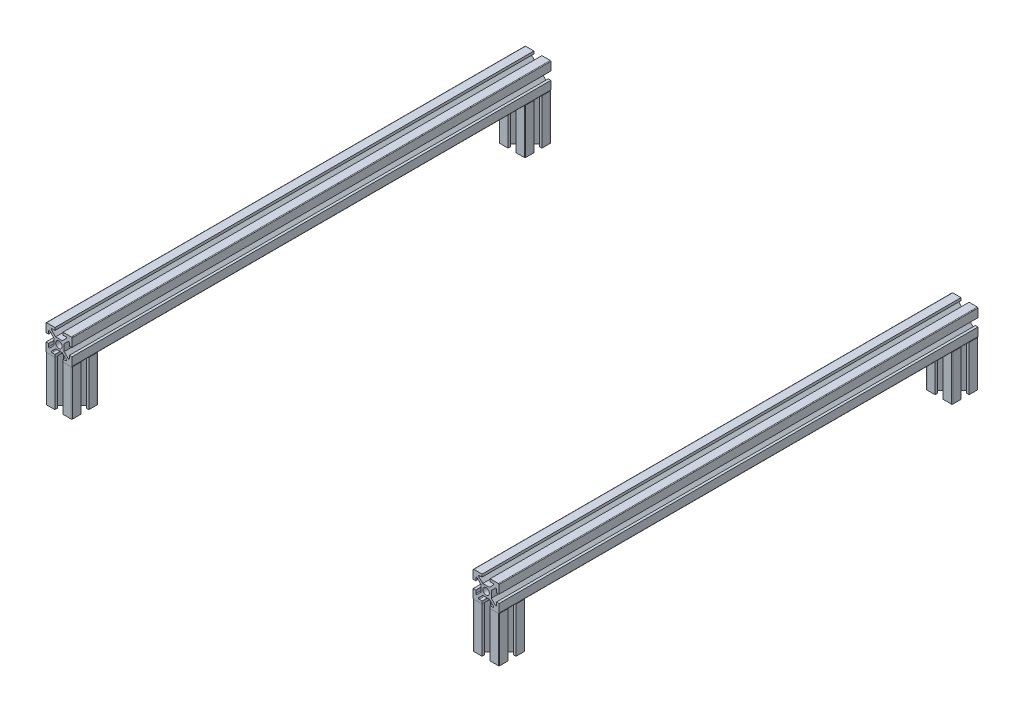
from build123d import *

# Parameters (mm, degrees)
SKETCH1_R                       = 2.5
AL_EXTRUSION_20X20_1_DEPTH      = 360
AL_EXTRUSION_20X20_1_DEPTH_BACK = 10
SKETCH1_ON_SEGMENT_2_R          = 2.5
AL_EXTRUSION_20X20_1_2_DEPTH    = 370
SKETCH1_ON_SEGMENT_3_R          = 2.5
AL_EXTRUSION_20X20_1_3_DEPTH    = 46
SKETCH1_ON_SEGMENT_4_R          = 2.5
AL_EXTRUSION_20X20_1_4_DEPTH    = 46
SKETCH1_ON_SEGMENT_5_R          = 2.5
AL_EXTRUSION_20X20_1_5_DEPTH    = 46
SKETCH1_ON_SEGMENT_6_R          = 2.5
AL_EXTRUSION_20X20_1_6_DEPTH    = 46


with BuildPart() as part:
    # Sketch1 → Al extrusion 20X20(1) (new, two sides)
    with BuildSketch(Plane(origin=(-165, 0, -175), x_dir=(1, 0, 0), z_dir=(0, 0, 1))) as al_extrusion_20x20_1_sk:
        with BuildLine():
            Line((-9.5, 10), (-3.1, 10))
            Line((-3.1, 10), (-3.1, 8))
            Line((-3.1, 8), (-5.378679656, 8))
            ThreePointArc((-5.378679656, 8), (-5.840619423, 7.691341716), (-5.732233047, 7.146446609))
            Line((-5.732233047, 7.146446609), (-2.585786438, 4))
            Line((-2.585786438, 4), (2.585786438, 4))
            Line((2.585786438, 4), (5.732233047, 7.146446609))
            ThreePointArc((5.732233047, 7.146446609), (5.840619423, 7.691341716), (5.378679656, 8))
            Line((5.378679656, 8), (3.1, 8))
            Line((3.1, 8), (3.1, 10))
            Line((3.1, 10), (9.5, 10))
            ThreePointArc((9.5, 10), (9.853553391, 9.853553391), (10, 9.5))
            Line((10, 9.5), (10, 3.1))
            Line((10, 3.1), (8, 3.1))
            Line((8, 3.1), (8, 5.378679656))
            ThreePointArc((8, 5.378679656), (7.691341716, 5.840619423), (7.146446609, 5.732233047))
            Line((7.146446609, 5.732233047), (4, 2.585786438))
            Line((4, 2.585786438), (4, -2.585786438))
            Line((4, -2.585786438), (7.146446609, -5.732233047))
            ThreePointArc((7.146446609, -5.732233047), (7.691341716, -5.840619423), (8, -5.378679656))
            Line((8, -5.378679656), (8, -3.1))
            Line((8, -3.1), (10, -3.1))
            Line((10, -3.1), (10, -9.5))
            ThreePointArc((10, -9.5), (9.853553391, -9.853553391), (9.5, -10))
            Line((9.5, -10), (3.1, -10))
            Line((3.1, -10), (3.1, -8))
            Line((3.1, -8), (5.378679656, -8))
            ThreePointArc((5.378679656, -8), (5.840619423, -7.691341716), (5.732233047, -7.146446609))
            Line((5.732233047, -7.146446609), (2.585786438, -4))
            Line((2.585786438, -4), (-2.585786438, -4))
            Line((-2.585786438, -4), (-5.732233047, -7.146446609))
            ThreePointArc((-5.732233047, -7.146446609), (-5.840619423, -7.691341716), (-5.378679656, -8))
            Line((-5.378679656, -8), (-3.1, -8))
            Line((-3.1, -8), (-3.1, -10))
            Line((-3.1, -10), (-9.5, -10))
            ThreePointArc((-9.5, -10), (-9.853553391, -9.853553391), (-10, -9.5))
            Line((-10, -9.5), (-10, -3.1))
            Line((-10, -3.1), (-8, -3.1))
            Line((-8, -3.1), (-8, -5.378679656))
            ThreePointArc((-8, -5.378679656), (-7.691341716, -5.840619423), (-7.146446609, -5.732233047))
            Line((-7.146446609, -5.732233047), (-4, -2.585786438))
            Line((-4, -2.585786438), (-4, 2.585786438))
            Line((-4, 2.585786438), (-7.146446609, 5.732233047))
            ThreePointArc((-7.146446609, 5.732233047), (-7.691341716, 5.840619423), (-8, 5.378679656))
            Line((-8, 5.378679656), (-8, 3.1))
            Line((-8, 3.1), (-10, 3.1))
            Line((-10, 3.1), (-10, 9.5))
            ThreePointArc((-10, 9.5), (-9.853553391, 9.853553391), (-9.5, 10))
        make_face()
        Circle(SKETCH1_R, mode=Mode.SUBTRACT)
    extrude(amount=AL_EXTRUSION_20X20_1_DEPTH)
    extrude(al_extrusion_20x20_1_sk.sketch, amount=-AL_EXTRUSION_20X20_1_DEPTH_BACK)


with BuildPart() as body_2:
    # Sketch1 on segment 2 (carried to segment 2) → Al extrusion 20X20_1 2 (new body)
    with BuildSketch(Plane(origin=(165, 0, -185), x_dir=(1, 0, 0), z_dir=(0, 0, 1))):
        with BuildLine():
            Line((-9.5, 10), (-3.1, 10))
            Line((-3.1, 10), (-3.1, 8))
            Line((-3.1, 8), (-5.378679656, 8))
            ThreePointArc((-5.378679656, 8), (-5.840619423, 7.691341716), (-5.732233047, 7.146446609))
            Line((-5.732233047, 7.146446609), (-2.585786438, 4))
            Line((-2.585786438, 4), (2.585786438, 4))
            Line((2.585786438, 4), (5.732233047, 7.146446609))
            ThreePointArc((5.732233047, 7.146446609), (5.840619423, 7.691341716), (5.378679656, 8))
            Line((5.378679656, 8), (3.1, 8))
            Line((3.1, 8), (3.1, 10))
            Line((3.1, 10), (9.5, 10))
            ThreePointArc((9.5, 10), (9.853553391, 9.853553391), (10, 9.5))
            Line((10, 9.5), (10, 3.1))
            Line((10, 3.1), (8, 3.1))
            Line((8, 3.1), (8, 5.378679656))
            ThreePointArc((8, 5.378679656), (7.691341716, 5.840619423), (7.146446609, 5.732233047))
            Line((7.146446609, 5.732233047), (4, 2.585786438))
            Line((4, 2.585786438), (4, -2.585786438))
            Line((4, -2.585786438), (7.146446609, -5.732233047))
            ThreePointArc((7.146446609, -5.732233047), (7.691341716, -5.840619423), (8, -5.378679656))
            Line((8, -5.378679656), (8, -3.1))
            Line((8, -3.1), (10, -3.1))
            Line((10, -3.1), (10, -9.5))
            ThreePointArc((10, -9.5), (9.853553391, -9.853553391), (9.5, -10))
            Line((9.5, -10), (3.1, -10))
            Line((3.1, -10), (3.1, -8))
            Line((3.1, -8), (5.378679656, -8))
            ThreePointArc((5.378679656, -8), (5.840619423, -7.691341716), (5.732233047, -7.146446609))
            Line((5.732233047, -7.146446609), (2.585786438, -4))
            Line((2.585786438, -4), (-2.585786438, -4))
            Line((-2.585786438, -4), (-5.732233047, -7.146446609))
            ThreePointArc((-5.732233047, -7.146446609), (-5.840619423, -7.691341716), (-5.378679656, -8))
            Line((-5.378679656, -8), (-3.1, -8))
            Line((-3.1, -8), (-3.1, -10))
            Line((-3.1, -10), (-9.5, -10))
            ThreePointArc((-9.5, -10), (-9.853553391, -9.853553391), (-10, -9.5))
            Line((-10, -9.5), (-10, -3.1))
            Line((-10, -3.1), (-8, -3.1))
            Line((-8, -3.1), (-8, -5.378679656))
            ThreePointArc((-8, -5.378679656), (-7.691341716, -5.840619423), (-7.146446609, -5.732233047))
            Line((-7.146446609, -5.732233047), (-4, -2.585786438))
            Line((-4, -2.585786438), (-4, 2.585786438))
            Line((-4, 2.585786438), (-7.146446609, 5.732233047))
            ThreePointArc((-7.146446609, 5.732233047), (-7.691341716, 5.840619423), (-8, 5.378679656))
            Line((-8, 5.378679656), (-8, 3.1))
            Line((-8, 3.1), (-10, 3.1))
            Line((-10, 3.1), (-10, 9.5))
            ThreePointArc((-10, 9.5), (-9.853553391, 9.853553391), (-9.5, 10))
        make_face()
        Circle(SKETCH1_ON_SEGMENT_2_R, mode=Mode.SUBTRACT)
    extrude(amount=AL_EXTRUSION_20X20_1_2_DEPTH)


with BuildPart() as body_3:
    # Sketch1 on segment 3 (carried to segment 3) → Al extrusion 20X20_1 3 (new body)
    with BuildSketch(Plane(origin=(-165, 1, 175), x_dir=(1, 0, 0), z_dir=(0, -1, 0))):
        with BuildLine():
            Line((-9.5, 10), (-3.1, 10))
            Line((-3.1, 10), (-3.1, 8))
            Line((-3.1, 8), (-5.378679656, 8))
            ThreePointArc((-5.378679656, 8), (-5.840619423, 7.691341716), (-5.732233047, 7.146446609))
            Line((-5.732233047, 7.146446609), (-2.585786438, 4))
            Line((-2.585786438, 4), (2.585786438, 4))
            Line((2.585786438, 4), (5.732233047, 7.146446609))
            ThreePointArc((5.732233047, 7.146446609), (5.840619423, 7.691341716), (5.378679656, 8))
            Line((5.378679656, 8), (3.1, 8))
            Line((3.1, 8), (3.1, 10))
            Line((3.1, 10), (9.5, 10))
            ThreePointArc((9.5, 10), (9.853553391, 9.853553391), (10, 9.5))
            Line((10, 9.5), (10, 3.1))
            Line((10, 3.1), (8, 3.1))
            Line((8, 3.1), (8, 5.378679656))
            ThreePointArc((8, 5.378679656), (7.691341716, 5.840619423), (7.146446609, 5.732233047))
            Line((7.146446609, 5.732233047), (4, 2.585786438))
            Line((4, 2.585786438), (4, -2.585786438))
            Line((4, -2.585786438), (7.146446609, -5.732233047))
            ThreePointArc((7.146446609, -5.732233047), (7.691341716, -5.840619423), (8, -5.378679656))
            Line((8, -5.378679656), (8, -3.1))
            Line((8, -3.1), (10, -3.1))
            Line((10, -3.1), (10, -9.5))
            ThreePointArc((10, -9.5), (9.853553391, -9.853553391), (9.5, -10))
            Line((9.5, -10), (3.1, -10))
            Line((3.1, -10), (3.1, -8))
            Line((3.1, -8), (5.378679656, -8))
            ThreePointArc((5.378679656, -8), (5.840619423, -7.691341716), (5.732233047, -7.146446609))
            Line((5.732233047, -7.146446609), (2.585786438, -4))
            Line((2.585786438, -4), (-2.585786438, -4))
            Line((-2.585786438, -4), (-5.732233047, -7.146446609))
            ThreePointArc((-5.732233047, -7.146446609), (-5.840619423, -7.691341716), (-5.378679656, -8))
            Line((-5.378679656, -8), (-3.1, -8))
            Line((-3.1, -8), (-3.1, -10))
            Line((-3.1, -10), (-9.5, -10))
            ThreePointArc((-9.5, -10), (-9.853553391, -9.853553391), (-10, -9.5))
            Line((-10, -9.5), (-10, -3.1))
            Line((-10, -3.1), (-8, -3.1))
            Line((-8, -3.1), (-8, -5.378679656))
            ThreePointArc((-8, -5.378679656), (-7.691341716, -5.840619423), (-7.146446609, -5.732233047))
            Line((-7.146446609, -5.732233047), (-4, -2.585786438))
            Line((-4, -2.585786438), (-4, 2.585786438))
            Line((-4, 2.585786438), (-7.146446609, 5.732233047))
            ThreePointArc((-7.146446609, 5.732233047), (-7.691341716, 5.840619423), (-8, 5.378679656))
            Line((-8, 5.378679656), (-8, 3.1))
            Line((-8, 3.1), (-10, 3.1))
            Line((-10, 3.1), (-10, 9.5))
            ThreePointArc((-10, 9.5), (-9.853553391, 9.853553391), (-9.5, 10))
        make_face()
        Circle(SKETCH1_ON_SEGMENT_3_R, mode=Mode.SUBTRACT)
    extrude(amount=AL_EXTRUSION_20X20_1_3_DEPTH)

    # Al extrusion 20X20_1 3 end butt 1
    split(bisect_by=Plane(origin=(-165, -10, 175), x_dir=(1, 0, 0), z_dir=(0, -1, 0)), keep=Keep.TOP)


with BuildPart() as body_4:
    # Sketch1 on segment 4 (carried to segment 4) → Al extrusion 20X20_1 4 (new body)
    with BuildSketch(Plane(origin=(-165, 1, -175), x_dir=(1, 0, 0), z_dir=(0, -1, 0))):
        with BuildLine():
            Line((-9.5, 10), (-3.1, 10))
            Line((-3.1, 10), (-3.1, 8))
            Line((-3.1, 8), (-5.378679656, 8))
            ThreePointArc((-5.378679656, 8), (-5.840619423, 7.691341716), (-5.732233047, 7.146446609))
            Line((-5.732233047, 7.146446609), (-2.585786438, 4))
            Line((-2.585786438, 4), (2.585786438, 4))
            Line((2.585786438, 4), (5.732233047, 7.146446609))
            ThreePointArc((5.732233047, 7.146446609), (5.840619423, 7.691341716), (5.378679656, 8))
            Line((5.378679656, 8), (3.1, 8))
            Line((3.1, 8), (3.1, 10))
            Line((3.1, 10), (9.5, 10))
            ThreePointArc((9.5, 10), (9.853553391, 9.853553391), (10, 9.5))
            Line((10, 9.5), (10, 3.1))
            Line((10, 3.1), (8, 3.1))
            Line((8, 3.1), (8, 5.378679656))
            ThreePointArc((8, 5.378679656), (7.691341716, 5.840619423), (7.146446609, 5.732233047))
            Line((7.146446609, 5.732233047), (4, 2.585786438))
            Line((4, 2.585786438), (4, -2.585786438))
            Line((4, -2.585786438), (7.146446609, -5.732233047))
            ThreePointArc((7.146446609, -5.732233047), (7.691341716, -5.840619423), (8, -5.378679656))
            Line((8, -5.378679656), (8, -3.1))
            Line((8, -3.1), (10, -3.1))
            Line((10, -3.1), (10, -9.5))
            ThreePointArc((10, -9.5), (9.853553391, -9.853553391), (9.5, -10))
            Line((9.5, -10), (3.1, -10))
            Line((3.1, -10), (3.1, -8))
            Line((3.1, -8), (5.378679656, -8))
            ThreePointArc((5.378679656, -8), (5.840619423, -7.691341716), (5.732233047, -7.146446609))
            Line((5.732233047, -7.146446609), (2.585786438, -4))
            Line((2.585786438, -4), (-2.585786438, -4))
            Line((-2.585786438, -4), (-5.732233047, -7.146446609))
            ThreePointArc((-5.732233047, -7.146446609), (-5.840619423, -7.691341716), (-5.378679656, -8))
            Line((-5.378679656, -8), (-3.1, -8))
            Line((-3.1, -8), (-3.1, -10))
            Line((-3.1, -10), (-9.5, -10))
            ThreePointArc((-9.5, -10), (-9.853553391, -9.853553391), (-10, -9.5))
            Line((-10, -9.5), (-10, -3.1))
            Line((-10, -3.1), (-8, -3.1))
            Line((-8, -3.1), (-8, -5.378679656))
            ThreePointArc((-8, -5.378679656), (-7.691341716, -5.840619423), (-7.146446609, -5.732233047))
            Line((-7.146446609, -5.732233047), (-4, -2.585786438))
            Line((-4, -2.585786438), (-4, 2.585786438))
            Line((-4, 2.585786438), (-7.146446609, 5.732233047))
            ThreePointArc((-7.146446609, 5.732233047), (-7.691341716, 5.840619423), (-8, 5.378679656))
            Line((-8, 5.378679656), (-8, 3.1))
            Line((-8, 3.1), (-10, 3.1))
            Line((-10, 3.1), (-10, 9.5))
            ThreePointArc((-10, 9.5), (-9.853553391, 9.853553391), (-9.5, 10))
        make_face()
        Circle(SKETCH1_ON_SEGMENT_4_R, mode=Mode.SUBTRACT)
    extrude(amount=AL_EXTRUSION_20X20_1_4_DEPTH)

    # Al extrusion 20X20_1 4 end butt 1
    split(bisect_by=Plane(origin=(-165, -10, -175), x_dir=(1, 0, 0), z_dir=(0, -1, 0)), keep=Keep.TOP)


with BuildPart() as body_5:
    # Sketch1 on segment 5 (carried to segment 5) → Al extrusion 20X20_1 5 (new body)
    with BuildSketch(Plane(origin=(165, 1, -175), x_dir=(1, 0, 0), z_dir=(0, -1, 0))):
        with BuildLine():
            Line((-9.5, 10), (-3.1, 10))
            Line((-3.1, 10), (-3.1, 8))
            Line((-3.1, 8), (-5.378679656, 8))
            ThreePointArc((-5.378679656, 8), (-5.840619423, 7.691341716), (-5.732233047, 7.146446609))
            Line((-5.732233047, 7.146446609), (-2.585786438, 4))
            Line((-2.585786438, 4), (2.585786438, 4))
            Line((2.585786438, 4), (5.732233047, 7.146446609))
            ThreePointArc((5.732233047, 7.146446609), (5.840619423, 7.691341716), (5.378679656, 8))
            Line((5.378679656, 8), (3.1, 8))
            Line((3.1, 8), (3.1, 10))
            Line((3.1, 10), (9.5, 10))
            ThreePointArc((9.5, 10), (9.853553391, 9.853553391), (10, 9.5))
            Line((10, 9.5), (10, 3.1))
            Line((10, 3.1), (8, 3.1))
            Line((8, 3.1), (8, 5.378679656))
            ThreePointArc((8, 5.378679656), (7.691341716, 5.840619423), (7.146446609, 5.732233047))
            Line((7.146446609, 5.732233047), (4, 2.585786438))
            Line((4, 2.585786438), (4, -2.585786438))
            Line((4, -2.585786438), (7.146446609, -5.732233047))
            ThreePointArc((7.146446609, -5.732233047), (7.691341716, -5.840619423), (8, -5.378679656))
            Line((8, -5.378679656), (8, -3.1))
            Line((8, -3.1), (10, -3.1))
            Line((10, -3.1), (10, -9.5))
            ThreePointArc((10, -9.5), (9.853553391, -9.853553391), (9.5, -10))
            Line((9.5, -10), (3.1, -10))
            Line((3.1, -10), (3.1, -8))
            Line((3.1, -8), (5.378679656, -8))
            ThreePointArc((5.378679656, -8), (5.840619423, -7.691341716), (5.732233047, -7.146446609))
            Line((5.732233047, -7.146446609), (2.585786438, -4))
            Line((2.585786438, -4), (-2.585786438, -4))
            Line((-2.585786438, -4), (-5.732233047, -7.146446609))
            ThreePointArc((-5.732233047, -7.146446609), (-5.840619423, -7.691341716), (-5.378679656, -8))
            Line((-5.378679656, -8), (-3.1, -8))
            Line((-3.1, -8), (-3.1, -10))
            Line((-3.1, -10), (-9.5, -10))
            ThreePointArc((-9.5, -10), (-9.853553391, -9.853553391), (-10, -9.5))
            Line((-10, -9.5), (-10, -3.1))
            Line((-10, -3.1), (-8, -3.1))
            Line((-8, -3.1), (-8, -5.378679656))
            ThreePointArc((-8, -5.378679656), (-7.691341716, -5.840619423), (-7.146446609, -5.732233047))
            Line((-7.146446609, -5.732233047), (-4, -2.585786438))
            Line((-4, -2.585786438), (-4, 2.585786438))
            Line((-4, 2.585786438), (-7.146446609, 5.732233047))
            ThreePointArc((-7.146446609, 5.732233047), (-7.691341716, 5.840619423), (-8, 5.378679656))
            Line((-8, 5.378679656), (-8, 3.1))
            Line((-8, 3.1), (-10, 3.1))
            Line((-10, 3.1), (-10, 9.5))
            ThreePointArc((-10, 9.5), (-9.853553391, 9.853553391), (-9.5, 10))
        make_face()
        Circle(SKETCH1_ON_SEGMENT_5_R, mode=Mode.SUBTRACT)
    extrude(amount=AL_EXTRUSION_20X20_1_5_DEPTH)

    # Al extrusion 20X20_1 5 end butt 1
    split(bisect_by=Plane(origin=(165, -10, -175), x_dir=(1, 0, 0), z_dir=(0, -1, 0)), keep=Keep.TOP)


with BuildPart() as body_6:
    # Sketch1 on segment 6 (carried to segment 6) → Al extrusion 20X20_1 6 (new body)
    with BuildSketch(Plane(origin=(165, 1, 175), x_dir=(1, 0, 0), z_dir=(0, -1, 0))):
        with BuildLine():
            Line((-9.5, 10), (-3.1, 10))
            Line((-3.1, 10), (-3.1, 8))
            Line((-3.1, 8), (-5.378679656, 8))
            ThreePointArc((-5.378679656, 8), (-5.840619423, 7.691341716), (-5.732233047, 7.146446609))
            Line((-5.732233047, 7.146446609), (-2.585786438, 4))
            Line((-2.585786438, 4), (2.585786438, 4))
            Line((2.585786438, 4), (5.732233047, 7.146446609))
            ThreePointArc((5.732233047, 7.146446609), (5.840619423, 7.691341716), (5.378679656, 8))
            Line((5.378679656, 8), (3.1, 8))
            Line((3.1, 8), (3.1, 10))
            Line((3.1, 10), (9.5, 10))
            ThreePointArc((9.5, 10), (9.853553391, 9.853553391), (10, 9.5))
            Line((10, 9.5), (10, 3.1))
            Line((10, 3.1), (8, 3.1))
            Line((8, 3.1), (8, 5.378679656))
            ThreePointArc((8, 5.378679656), (7.691341716, 5.840619423), (7.146446609, 5.732233047))
            Line((7.146446609, 5.732233047), (4, 2.585786438))
            Line((4, 2.585786438), (4, -2.585786438))
            Line((4, -2.585786438), (7.146446609, -5.732233047))
            ThreePointArc((7.146446609, -5.732233047), (7.691341716, -5.840619423), (8, -5.378679656))
            Line((8, -5.378679656), (8, -3.1))
            Line((8, -3.1), (10, -3.1))
            Line((10, -3.1), (10, -9.5))
            ThreePointArc((10, -9.5), (9.853553391, -9.853553391), (9.5, -10))
            Line((9.5, -10), (3.1, -10))
            Line((3.1, -10), (3.1, -8))
            Line((3.1, -8), (5.378679656, -8))
            ThreePointArc((5.378679656, -8), (5.840619423, -7.691341716), (5.732233047, -7.146446609))
            Line((5.732233047, -7.146446609), (2.585786438, -4))
            Line((2.585786438, -4), (-2.585786438, -4))
            Line((-2.585786438, -4), (-5.732233047, -7.146446609))
            ThreePointArc((-5.732233047, -7.146446609), (-5.840619423, -7.691341716), (-5.378679656, -8))
            Line((-5.378679656, -8), (-3.1, -8))
            Line((-3.1, -8), (-3.1, -10))
            Line((-3.1, -10), (-9.5, -10))
            ThreePointArc((-9.5, -10), (-9.853553391, -9.853553391), (-10, -9.5))
            Line((-10, -9.5), (-10, -3.1))
            Line((-10, -3.1), (-8, -3.1))
            Line((-8, -3.1), (-8, -5.378679656))
            ThreePointArc((-8, -5.378679656), (-7.691341716, -5.840619423), (-7.146446609, -5.732233047))
            Line((-7.146446609, -5.732233047), (-4, -2.585786438))
            Line((-4, -2.585786438), (-4, 2.585786438))
            Line((-4, 2.585786438), (-7.146446609, 5.732233047))
            ThreePointArc((-7.146446609, 5.732233047), (-7.691341716, 5.840619423), (-8, 5.378679656))
            Line((-8, 5.378679656), (-8, 3.1))
            Line((-8, 3.1), (-10, 3.1))
            Line((-10, 3.1), (-10, 9.5))
            ThreePointArc((-10, 9.5), (-9.853553391, 9.853553391), (-9.5, 10))
        make_face()
        Circle(SKETCH1_ON_SEGMENT_6_R, mode=Mode.SUBTRACT)
    extrude(amount=AL_EXTRUSION_20X20_1_6_DEPTH)

    # Al extrusion 20X20_1 6 end butt 1
    split(bisect_by=Plane(origin=(165, -10, 175), x_dir=(1, 0, 0), z_dir=(0, -1, 0)), keep=Keep.TOP)


solid = Compound([part.part, body_2.part, body_3.part, body_4.part, body_5.part, body_6.part])
